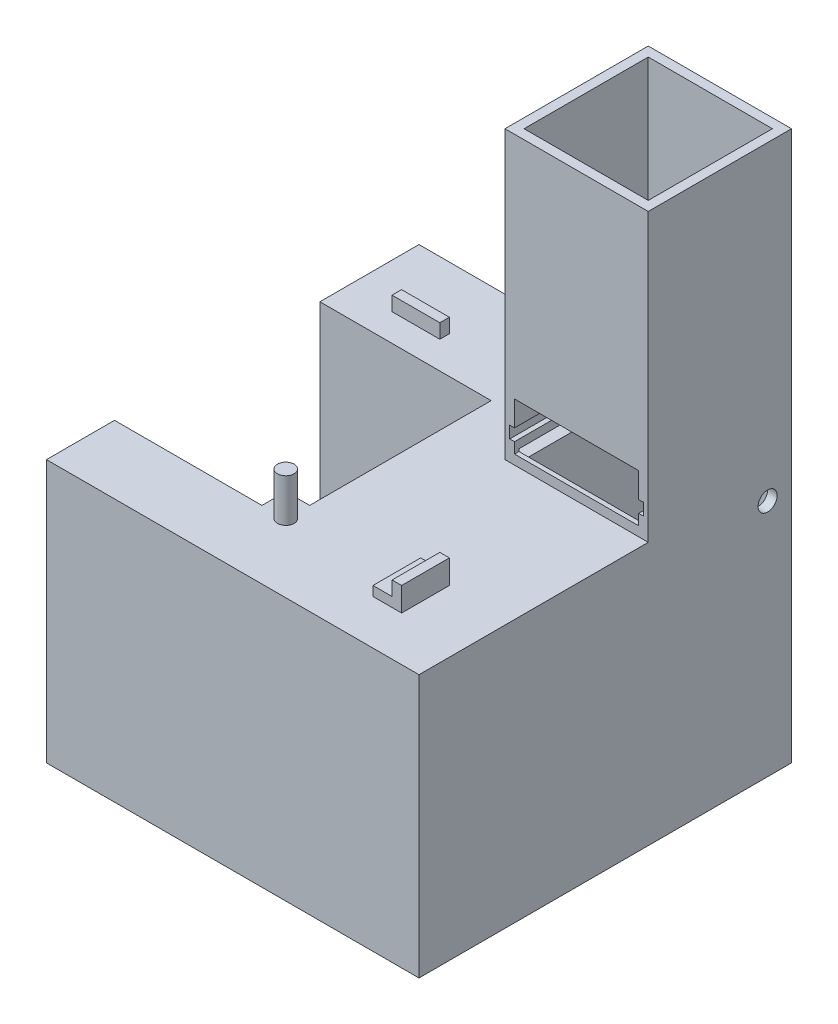
from build123d import *

# Parameters (mm, degrees)
SKETCH1_W            = 78
SKETCH1_H            = 78
BOSS_EXTRUDE1_DEPTH  = 2
SKETCH2_W            = 30
SKETCH2_H            = 30
BOSS_EXTRUDE2_DEPTH  = 60
SKETCH3_W            = 26
SKETCH3_H            = 26
CUT_EXTRUDE1_DEPTH   = 62
SKETCH4_W            = 28
SKETCH4_H            = 2.5
CUT_EXTRUDE2_DEPTH   = 28
SKETCH5_W            = 26
SKETCH5_H            = 10
CUT_EXTRUDE3_DEPTH   = 2
SKETCH6_W            = 28
SKETCH6_H            = 2.5
CUT_EXTRUDE4_DEPTH   = 1
SKETCH7_W            = 28
SKETCH7_H            = 2.5
CUT_EXTRUDE5_DEPTH   = 1
SKETCH14_R           = 1.75
BOSS_EXTRUDE8_DEPTH  = 5
SKETCH16_W           = 4
SKETCH16_H           = 5
BOSS_EXTRUDE10_DEPTH = 2
SKETCH17_W           = 2
SKETCH17_H           = 10
BOSS_EXTRUDE11_DEPTH = 5
SKETCH18_W           = 10
SKETCH18_H           = 2
BOSS_EXTRUDE12_DEPTH = 3
SKETCH21_W           = 78
SKETCH21_H           = 78
BOSS_EXTRUDE13_DEPTH = 53
SKETCH15_W           = 43
SKETCH15_H           = 43
CUT_EXTRUDE6_DEPTH   = 53
SKETCH23_W           = 5
SKETCH23_H           = 2
BOSS_EXTRUDE15_DEPTH = 5
SKETCH24_W           = 26
SKETCH24_H           = 26
CUT_EXTRUDE9_DEPTH   = 51
SKETCH27_W           = 26
SKETCH27_H           = 26
CUT_EXTRUDE10_DEPTH  = 2
BOSS_EXTRUDE16_DEPTH = 26
SKETCH31_W           = 13
SKETCH31_H           = 13
CUT_EXTRUDE12_DEPTH  = 10
SKETCH32_R           = 2
CUT_EXTRUDE13_DEPTH  = 2
SKETCH33_R           = 2
CUT_EXTRUDE14_DEPTH  = 2
SKETCH36_R           = 1.75
BOSS_EXTRUDE17_DEPTH = 4


with BuildPart() as part:
    # Sketch1 → Boss-Extrude1 (new body)
    with BuildSketch(Plane(origin=(0, 0, 0), x_dir=(1, 0, 0), z_dir=(0, 1, 0))):
        Rectangle(SKETCH1_W, SKETCH1_H)
    extrude(amount=BOSS_EXTRUDE1_DEPTH)

    # Sketch2 → Boss-Extrude2 (add)
    with BuildSketch(Plane(origin=(0, 2, 0), x_dir=(1, 0, 0), z_dir=(0, 1, 0))):
        with Locations((24, 24)):
            Rectangle(SKETCH2_W, SKETCH2_H)
    extrude(amount=BOSS_EXTRUDE2_DEPTH)

    # Sketch3 → Cut-Extrude1 (cut)
    with BuildSketch(Plane(origin=(0, 62, 0), x_dir=(1, 0, 0), z_dir=(0, 1, 0))):
        with Locations((24, 24)):
            Rectangle(SKETCH3_W, SKETCH3_H)
    extrude(amount=-CUT_EXTRUDE1_DEPTH, mode=Mode.SUBTRACT)

    # Sketch4 → Cut-Extrude2 (cut)
    with BuildSketch(Plane.ZY.offset(-9)):
        with Locations((-23.934548619, 3.25)):
            Rectangle(SKETCH4_W, SKETCH4_H)
    extrude(amount=-CUT_EXTRUDE2_DEPTH, mode=Mode.SUBTRACT)

    # Sketch5 → Cut-Extrude3 (cut)
    with BuildSketch(Plane.XY.offset(-9)):
        with Locations((24, 9)):
            Rectangle(SKETCH5_W, SKETCH5_H)
    extrude(amount=-CUT_EXTRUDE3_DEPTH, mode=Mode.SUBTRACT)

    # Sketch6 → Cut-Extrude4 (cut)
    with BuildSketch(Plane.ZY.offset(-37)):
        with Locations((-23, 7.5)):
            Rectangle(SKETCH6_W, SKETCH6_H)
    extrude(amount=-CUT_EXTRUDE4_DEPTH, mode=Mode.SUBTRACT)

    # Sketch7 → Cut-Extrude5 (cut)
    with BuildSketch(Plane(origin=(11, 0, 0), x_dir=(0, 0, -1), z_dir=(1, 0, 0))):
        with Locations((23, 7.5)):
            Rectangle(SKETCH7_W, SKETCH7_H)
    extrude(amount=-CUT_EXTRUDE5_DEPTH, mode=Mode.SUBTRACT)

    # Sketch14 → Boss-Extrude8 (add)
    with BuildSketch(Plane(origin=(0, 2, 0), x_dir=(1, 0, 0), z_dir=(0, 1, 0))):
        with Locations((-3.25, -24.64)):
            Circle(SKETCH14_R)
    extrude(amount=BOSS_EXTRUDE8_DEPTH)

    # Sketch16 → Boss-Extrude10 (add)
    with BuildSketch(Plane(origin=(0, 2, 0), x_dir=(1, 0, 0), z_dir=(0, 1, 0))):
        with Locations((22, -22.14)):
            Rectangle(SKETCH16_W, SKETCH16_H)
        with Locations((22, -27.14)):
            Rectangle(SKETCH16_W, SKETCH16_H)
    extrude(amount=BOSS_EXTRUDE10_DEPTH)

    # Sketch17 → Boss-Extrude11 (add)
    with BuildSketch(Plane(origin=(0, 2, 0), x_dir=(1, 0, 0), z_dir=(0, 1, 0))):
        with Locations((25, -24.64)):
            Rectangle(SKETCH17_W, SKETCH17_H)
    extrude(amount=BOSS_EXTRUDE11_DEPTH)

    # Sketch18 → Boss-Extrude12 (add)
    with BuildSketch(Plane(origin=(0, 2, 0), x_dir=(1, 0, 0), z_dir=(0, 1, 0))):
        with Locations((-24.64, 25)):
            Rectangle(SKETCH18_W, SKETCH18_H)
    extrude(amount=BOSS_EXTRUDE12_DEPTH)

    # Sketch21 → Boss-Extrude13 (add)
    with BuildSketch(Plane.XZ):
        Rectangle(SKETCH21_W, SKETCH21_H)
    extrude(amount=BOSS_EXTRUDE13_DEPTH)

    # Sketch15 → Cut-Extrude6 (cut)
    with BuildSketch(Plane(origin=(0, 2, 0), x_dir=(1, 0, 0), z_dir=(0, 1, 0))):
        with Locations((-24.64, -3.25)):
            Rectangle(SKETCH15_W, SKETCH15_H)
    extrude(amount=-CUT_EXTRUDE6_DEPTH, mode=Mode.SUBTRACT)

    # Sketch23 → Boss-Extrude15 (add)
    with BuildSketch(Plane.ZY.offset(3.14)):
        with Locations((22.25, 1)):
            Rectangle(SKETCH23_W, SKETCH23_H)
    extrude(amount=BOSS_EXTRUDE15_DEPTH)

    # Sketch24 → Cut-Extrude9 (cut)
    with BuildSketch(Plane(origin=(0, 0, 0), x_dir=(1, 0, 0), z_dir=(0, 1, 0))):
        with Locations((24, 24)):
            Rectangle(SKETCH24_W, SKETCH24_H)
    extrude(amount=-CUT_EXTRUDE9_DEPTH, mode=Mode.SUBTRACT)

    # Sketch27 → Cut-Extrude10 (cut)
    with BuildSketch(Plane(origin=(0, 0, -39), x_dir=(-1, 0, 0), z_dir=(0, 0, -1))):
        with Locations((-24, -38)):
            Rectangle(SKETCH27_W, SKETCH27_H)
    extrude(amount=-CUT_EXTRUDE10_DEPTH, mode=Mode.SUBTRACT)

    # Sketch28 → Boss-Extrude16 (add)
    with BuildSketch(Plane(origin=(11, 0, 0), x_dir=(0, 0, -1), z_dir=(1, 0, 0))):
        Polygon((39, -51), (11, -51), (11, -24.5), align=None)
    extrude(amount=BOSS_EXTRUDE16_DEPTH)

    # Sketch31 → Cut-Extrude12 (cut)
    with BuildSketch(Plane(origin=(0, 2, 0), x_dir=(1, 0, 0), z_dir=(0, 1, 0))):
        with Locations((2.5, 32.5)):
            Rectangle(SKETCH31_W, SKETCH31_H)
    extrude(amount=-CUT_EXTRUDE12_DEPTH, mode=Mode.SUBTRACT)

    # Sketch32 → Cut-Extrude13 (cut)
    with BuildSketch(Plane(origin=(39, 0, 0), x_dir=(0, 0, -1), z_dir=(1, 0, 0))):
        with Locations((34, -3)):
            Circle(SKETCH32_R)
    extrude(amount=-CUT_EXTRUDE13_DEPTH, mode=Mode.SUBTRACT)

    # Sketch33 → Cut-Extrude14 (cut)
    with BuildSketch(Plane(origin=(11, 0, 0), x_dir=(0, 0, -1), z_dir=(1, 0, 0))):
        with Locations((34, -3)):
            Circle(SKETCH33_R)
    extrude(amount=-CUT_EXTRUDE14_DEPTH, mode=Mode.SUBTRACT)

    # Sketch36 → Boss-Extrude17 (add)
    with BuildSketch(Plane(origin=(0, 7, 0), x_dir=(1, 0, 0), z_dir=(0, 1, 0))):
        with Locations((-3.25, -24.64)):
            Circle(SKETCH36_R)
    extrude(amount=BOSS_EXTRUDE17_DEPTH)


solid = part.part
